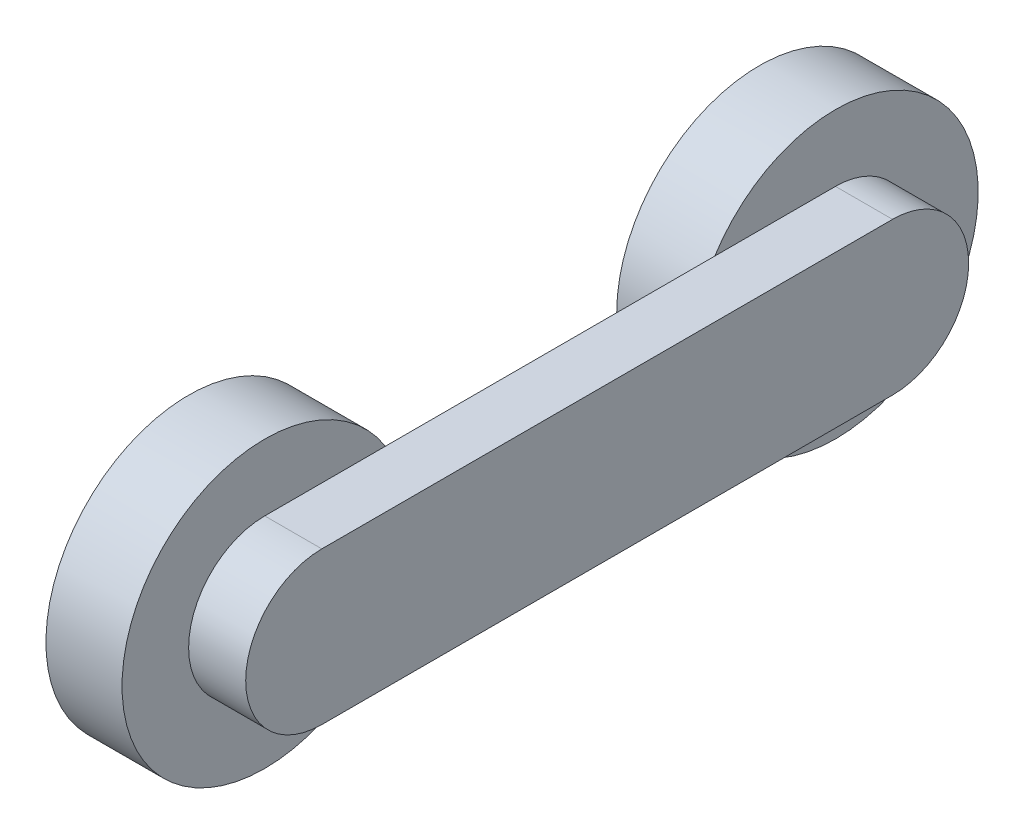
from build123d import *

# Parameters (mm, degrees)
SKETCH1_R           = 75
BOSS_EXTRUDE1_DEPTH = 40
BOSS_EXTRUDE2_DEPTH = 30
SKETCH3_R           = 75
BOSS_EXTRUDE3_DEPTH = 40


with BuildPart() as part:
    # Sketch1 → Boss-Extrude1 (new body)
    with BuildSketch(Plane(origin=(0, 0, 0), x_dir=(0, 0, -1), z_dir=(1, 0, 0))):
        Circle(SKETCH1_R)
    extrude(amount=BOSS_EXTRUDE1_DEPTH)

    # Sketch2 → Boss-Extrude2 (add)
    with BuildSketch(Plane(origin=(40, 0, 0), x_dir=(0, 0, -1), z_dir=(1, 0, 0))):
        with BuildLine():
            Line((0, 40), (300, 40))
            ThreePointArc((300, 40), (340, 0), (300, -40))
            Line((300, -40), (0, -40))
            ThreePointArc((0, -40), (-40, 0), (0, 40))
        make_face()
    extrude(amount=BOSS_EXTRUDE2_DEPTH)

    # Sketch3 → Boss-Extrude3 (add)
    with BuildSketch(Plane.ZY.offset(-40)):
        with Locations((-300, 0)):
            Circle(SKETCH3_R)
    extrude(amount=BOSS_EXTRUDE3_DEPTH)


solid = part.part
